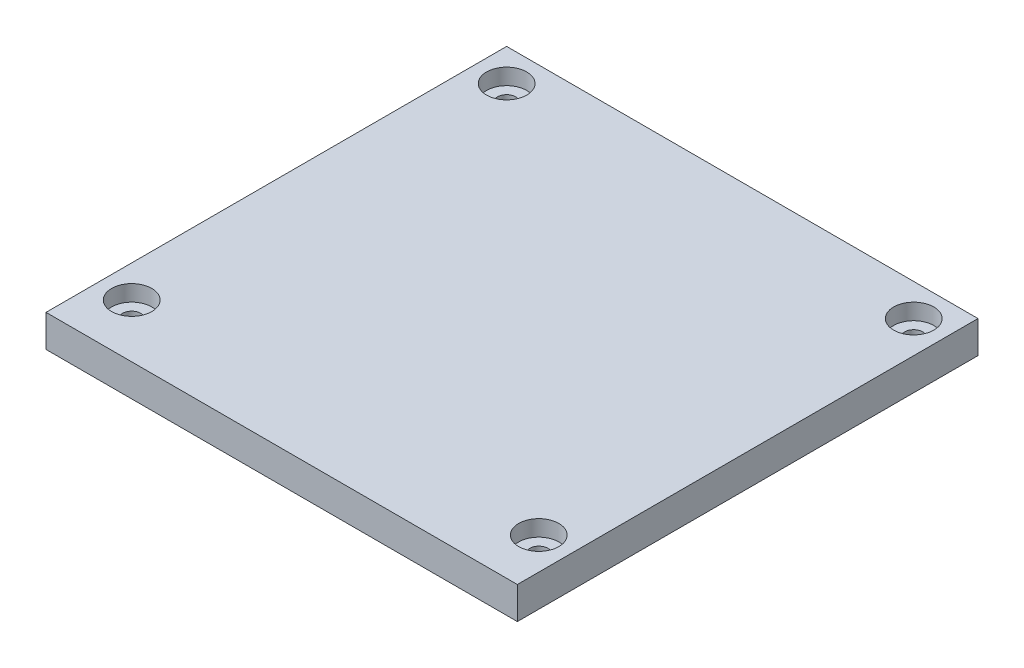
from build123d import *

# Parameters (mm, degrees)
SKETCH1_W           = 88
SKETCH1_H           = 82
BOSS_EXTRUDE1_DEPTH = 3
SKETCH2_R           = 1.7
CUT_EXTRUDE1_DEPTH  = 4
SKETCH4_W           = 81.2
SKETCH4_H           = 75.2
SKETCH4_W_2         = 75.2
SKETCH4_H_2         = 69.2
BOSS_EXTRUDE2_DEPTH = 2
CUT_EXTRUDE5_START  = -3
SKETCH6_R           = 6
CUT_EXTRUDE5_DEPTH  = 3
SKETCH7_W           = 88
SKETCH7_H           = 3
BOSS_EXTRUDE3_DEPTH = 4
SKETCH8_R           = 3.75
BOSS_EXTRUDE4_DEPTH = 3


with BuildPart() as part:
    # Sketch1 → Boss-Extrude1 (new body)
    with BuildSketch(Plane(origin=(0, 0, 0), x_dir=(1, 0, 0), z_dir=(0, 1, 0))):
        Rectangle(SKETCH1_W, SKETCH1_H)
    extrude(amount=BOSS_EXTRUDE1_DEPTH)

    # Sketch2 → Cut-Extrude1 (cut, through all)
    with BuildSketch(Plane(origin=(0, 3, 0), x_dir=(1, 0, 0), z_dir=(0, 1, 0))):
        with Locations((-38, 35)):
            Circle(SKETCH2_R)
        with Locations((38, 35)):
            Circle(SKETCH2_R)
        with Locations((38, -35)):
            Circle(SKETCH2_R)
        with Locations((-38, -35)):
            Circle(SKETCH2_R)
    extrude(amount=-CUT_EXTRUDE1_DEPTH, mode=Mode.SUBTRACT)

    # Sketch4 → Boss-Extrude2 (add)
    with BuildSketch(Plane.XZ):
        Rectangle(SKETCH4_W, SKETCH4_H)
        Rectangle(SKETCH4_W_2, SKETCH4_H_2, mode=Mode.SUBTRACT)
    extrude(amount=BOSS_EXTRUDE2_DEPTH)

    # Sketch6 → Cut-Extrude5 (cut, through all)
    with BuildSketch(Plane(origin=(0, 3, 0), x_dir=(1, 0, 0), z_dir=(0, 1, 0)).offset(CUT_EXTRUDE5_START)):
        with Locations((-38, 35)):
            Circle(SKETCH6_R)
        with Locations((-38, -35)):
            Circle(SKETCH6_R)
        with Locations((38, -35)):
            Circle(SKETCH6_R)
        with Locations((38, 35)):
            Circle(SKETCH6_R)
    extrude(amount=-CUT_EXTRUDE5_DEPTH, mode=Mode.SUBTRACT)

    # Sketch7 → Boss-Extrude3 (add)
    with BuildSketch(Plane.XY.offset(41)):
        with Locations((0, 1.5)):
            Rectangle(SKETCH7_W, SKETCH7_H)
    extrude(amount=BOSS_EXTRUDE3_DEPTH)

    # Sketch8 → Boss-Extrude4 (add)
    with BuildSketch(Plane(origin=(0, 3, 0), x_dir=(1, 0, 0), z_dir=(0, 1, 0))):
        Polygon((-44, -41), (-44, -45), (44, -45), (44, -41), (44, 41), (-44, 41), align=None)
        with Locations((-38, 35)):
            Circle(SKETCH8_R, mode=Mode.SUBTRACT)
        with Locations((38, 35)):
            Circle(SKETCH8_R, mode=Mode.SUBTRACT)
        with Locations((-38, -35)):
            Circle(SKETCH8_R, mode=Mode.SUBTRACT)
        with Locations((38, -35)):
            Circle(SKETCH8_R, mode=Mode.SUBTRACT)
    extrude(amount=BOSS_EXTRUDE4_DEPTH)


solid = part.part
